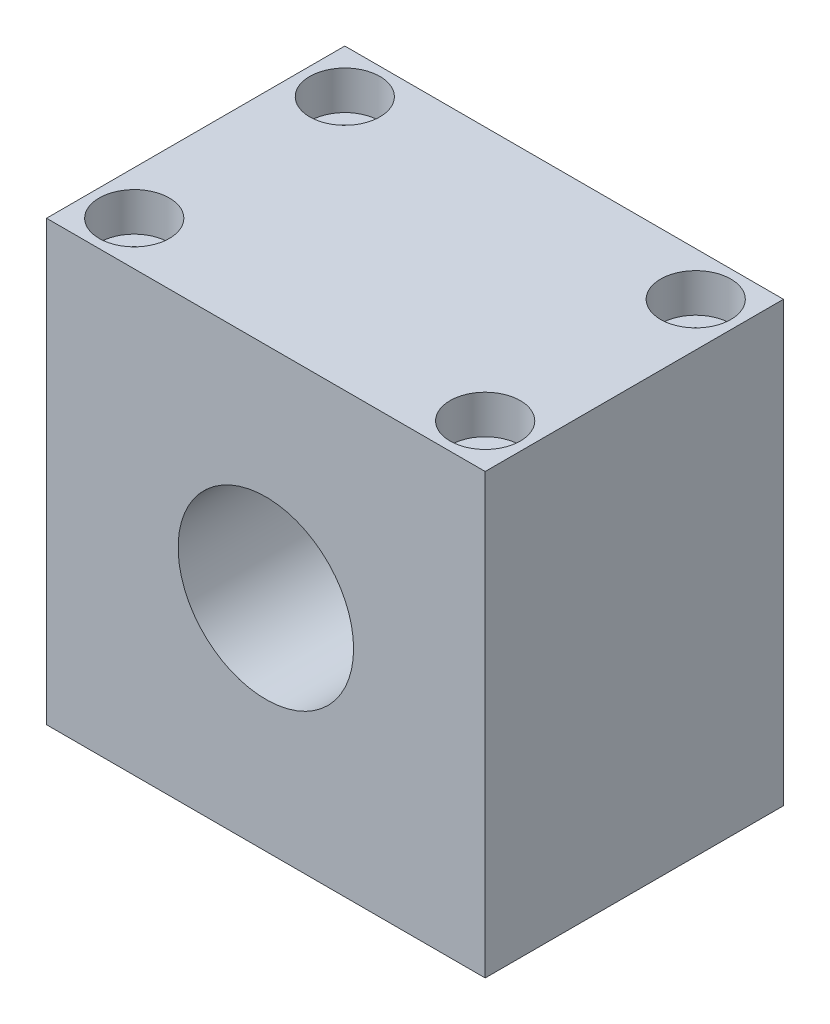
from build123d import *

# Parameters (mm, degrees)
SKETCH1_W                                           = 50
SKETCH1_H                                           = 50
BOSS_EXTRUDE1_DEPTH                                 = 34
CBORE_FOR_M4_HEX_SOCKET_HEAD_CAP_SCREW1_D           = 4.5
CBORE_FOR_M4_HEX_SOCKET_HEAD_CAP_SCREW1_CBORE_D     = 8
CBORE_FOR_M4_HEX_SOCKET_HEAD_CAP_SCREW1_CBORE_DEPTH = 4.4
SKETCH6_R                                           = 10
CUT_EXTRUDE1_DEPTH                                  = 35


with BuildPart() as part:
    # Sketch1 → Boss-Extrude1 (new body)
    with BuildSketch(Plane.XY):
        Rectangle(SKETCH1_W, SKETCH1_H)
    extrude(amount=BOSS_EXTRUDE1_DEPTH)

    # CBORE for M4 Hex Socket Head Cap Screw1 (through all)
    with Locations(Plane(origin=(0, 25, 0), x_dir=(1, 0, 0), z_dir=(0, 1, 0))):
        with Locations((-20, -5), (20, -5), (20, -29), (-20, -29)):
            CounterBoreHole(CBORE_FOR_M4_HEX_SOCKET_HEAD_CAP_SCREW1_D / 2, CBORE_FOR_M4_HEX_SOCKET_HEAD_CAP_SCREW1_CBORE_D / 2, CBORE_FOR_M4_HEX_SOCKET_HEAD_CAP_SCREW1_CBORE_DEPTH)

    # Sketch6 → Cut-Extrude1 (cut, through all)
    with BuildSketch(Plane.XY.offset(34)):
        Circle(SKETCH6_R)
    extrude(amount=-CUT_EXTRUDE1_DEPTH, mode=Mode.SUBTRACT)


solid = part.part
